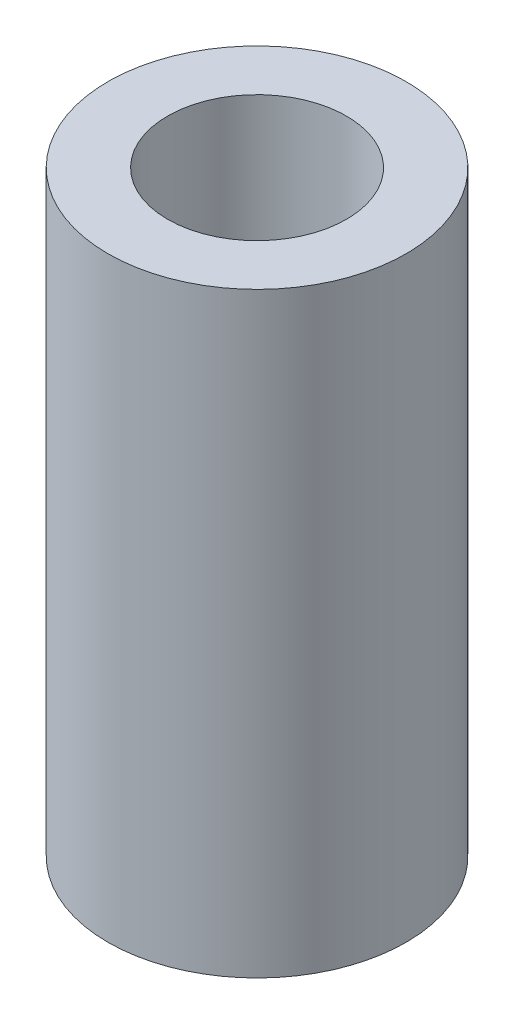
from build123d import *

# Parameters (mm, degrees)
SKETCH1_R                = 1
SKETCH1_R_2              = 0.5
BOSS_EXTRUDE1_DEPTH      = 1
SKETCH2_R                = 1
BOSS_EXTRUDE2_DEPTH      = 3
M1_CLEARANCE_HOLE1_D     = 1.2
M1_CLEARANCE_HOLE1_DEPTH = 2
M1_CLEARANCE_HOLE1_TIP   = 0.360516371


with BuildPart() as part:
    # Sketch1 → Boss-Extrude1 (new body)
    with BuildSketch(Plane(origin=(0, 0, 0), x_dir=(1, 0, 0), z_dir=(0, 1, 0))):
        Circle(SKETCH1_R)
        Circle(SKETCH1_R_2, mode=Mode.SUBTRACT)
    extrude(amount=BOSS_EXTRUDE1_DEPTH)

    # Sketch2 → Boss-Extrude2 (add)
    with BuildSketch(Plane(origin=(0, 1, 0), x_dir=(1, 0, 0), z_dir=(0, 1, 0))):
        Circle(SKETCH2_R)
    extrude(amount=BOSS_EXTRUDE2_DEPTH)

    # M1 Clearance Hole1
    with Locations(Plane(origin=(0, 4, 0), x_dir=(1, 0, 0), z_dir=(0, 1, 0))):
        with Locations((0, 0)):
            Hole(M1_CLEARANCE_HOLE1_D / 2, depth=M1_CLEARANCE_HOLE1_DEPTH)
            with Locations((0, 0, -(M1_CLEARANCE_HOLE1_DEPTH + M1_CLEARANCE_HOLE1_TIP / 2))):  # 118° drill point
                Cone(0, M1_CLEARANCE_HOLE1_D / 2, M1_CLEARANCE_HOLE1_TIP, mode=Mode.SUBTRACT)


solid = part.part
